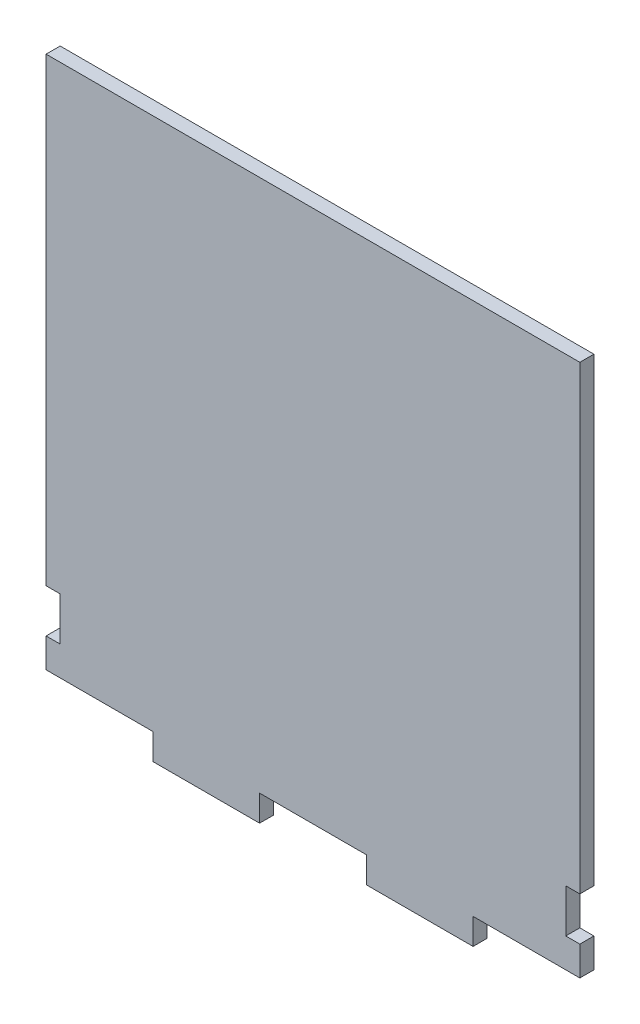
from build123d import *

# Parameters (mm, degrees)
BOSS_EXTRUDE1_DEPTH = 2.7


with BuildPart() as part:
    # Sketch1 → Boss-Extrude1 (new body)
    with BuildSketch(Plane.XY):
        Polygon((-51.2, -9.8), (-51.2, -4.166666667), (-48.5, -4.166666667), (-48.5, 4.166666667), (-51.2, 4.166666667), (-51.2, 92.5), (51.2, 92.5), (51.2, 4.166666667), (48.5, 4.166666667), (48.5, -4.166666667), (51.2, -4.166666667), (51.2, -9.8), (30.72, -9.8), (30.72, -12.5), (30.72, -14.8), (10.24, -14.8), (10.24, -12.5), (10.24, -9.8), (-10.24, -9.8), (-10.24, -12.5), (-10.24, -14.8), (-30.72, -14.8), (-30.72, -12.5), (-30.72, -9.8), align=None)
    extrude(amount=BOSS_EXTRUDE1_DEPTH)


solid = part.part
